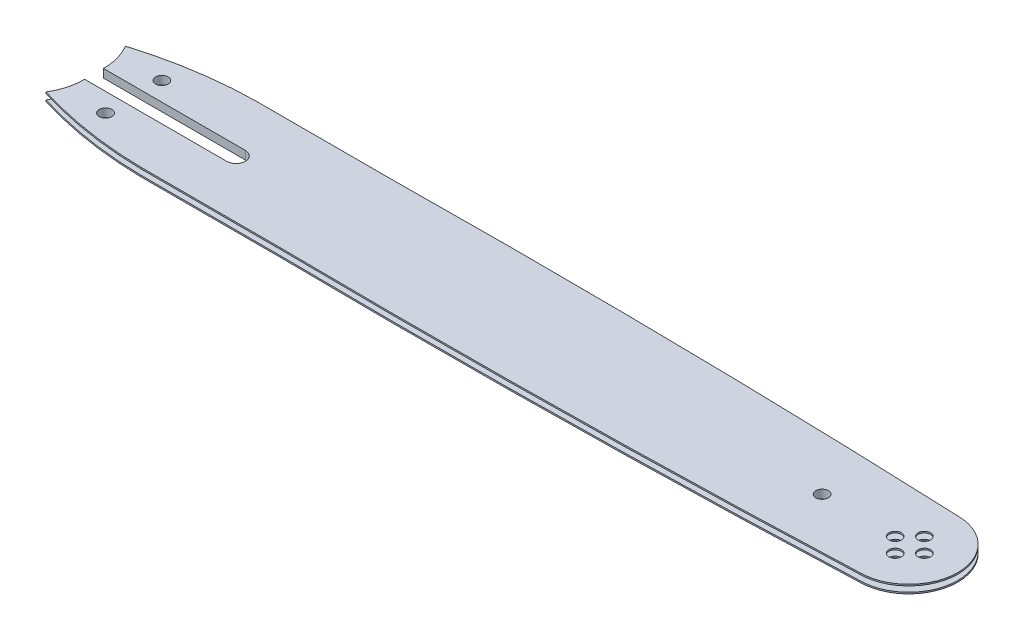
from build123d import *

# Parameters (mm, degrees)
BOSS_EXTRUDE2_DEPTH     = 4
SKETCH1_5_R             = 3
CUT_EXTRUDE3_DEPTH      = 54
SKETCH1_6_R             = 3
CUT_EXTRUDE4_DEPTH      = 35
CUT_EXTRUDE6_DEPTH      = 1.3
CUT_EXTRUDE6_DEPTH_BACK = 1.3


with BuildPart() as part:
    # Sketch1 → Boss-Extrude2 (new body)
    with BuildSketch(Plane(origin=(0, 0, 0), x_dir=(1, 0, 0), z_dir=(0, 1, 0))):
        with BuildLine():
            Line((-71.648984849, 27.5), (-138.40789612, 27.5))
            ThreePointArc((-138.40789612, 27.5), (-165.710949902, 25.175282852), (-192.40789612, 19))
            ThreePointArc((-192.40789612, 19), (-189.370573735, 12.036157899), (-188.40789612, 4.5))
            Line((-188.40789612, 4.5), (-120.40789612, 4.5))
            ThreePointArc((-120.40789612, 4.5), (-115.90789612, 0), (-120.40789612, -4.5))
            Line((-120.40789612, -4.5), (-188.40789612, -4.5))
            ThreePointArc((-188.40789612, -4.5), (-189.370573735, -12.036157899), (-192.40789612, -19))
            ThreePointArc((-192.40789612, -19), (-165.710949902, -25.175282852), (-138.40789612, -27.5))
            Line((-138.40789612, -27.5), (-71.648984849, -27.5))
            ThreePointArc((-71.648984849, -27.5), (65.101994969, -27.347428228), (201.798926373, -23.5))
            ThreePointArc((201.798926373, -23.5), (225.298926373, 0), (201.798926373, 23.5))
            ThreePointArc((201.798926373, 23.5), (65.101994969, 27.347428228), (-71.648984849, 27.5))
        make_face()
    extrude(amount=BOSS_EXTRUDE2_DEPTH)

    # Sketch1_5 → Cut-Extrude3 (cut)
    with BuildSketch(Plane(origin=(0, 0, 0), x_dir=(1, 0, 0), z_dir=(0, 1, 0))):
        with Locations((160.298926373, 0)):
            Circle(SKETCH1_5_R)
        with Locations((195.298926373, 0)):
            Circle(SKETCH1_5_R)
        with Locations((202.298926373, 7)):
            Circle(SKETCH1_5_R)
        with Locations((209.298926373, 0)):
            Circle(SKETCH1_5_R)
        with Locations((202.298926373, -7)):
            Circle(SKETCH1_5_R)
        with Locations((-169.40789612, -13.5)):
            Circle(SKETCH1_5_R)
    extrude(amount=CUT_EXTRUDE3_DEPTH, mode=Mode.SUBTRACT)

    # Sketch1_6 → Cut-Extrude4 (cut)
    with BuildSketch(Plane(origin=(0, 0, 0), x_dir=(1, 0, 0), z_dir=(0, 1, 0))):
        with Locations((-169.40789612, 13.5)):
            Circle(SKETCH1_6_R)
    extrude(amount=CUT_EXTRUDE4_DEPTH, mode=Mode.SUBTRACT)

    # Sketch11 → Cut-Extrude6 (cut, two sides: drawn at the far end of the back side and taken through both)
    with BuildSketch(Plane(origin=(0, 2, 0), x_dir=(1, 0, 0), z_dir=(0, 1, 0)).offset(-CUT_EXTRUDE6_DEPTH_BACK)):
        with BuildLine():
            Line((-138.380243773, -23.5), (-71.624188449, -23.5))
            ThreePointArc((-71.624188449, -23.5), (56.038931481, -23.471555382), (183.66064985, -20.220401783))
            ThreePointArc((183.66064985, -20.220401783), (174.798926373, 0), (183.66064985, 20.220401783))
            ThreePointArc((183.66064985, 20.220401783), (56.038931481, 23.471555382), (-71.624188449, 23.5))
            Line((-71.624188449, 23.5), (-138.380243773, 23.5))
            ThreePointArc((-138.380243773, 23.5), (-164.744814342, 21.277783148), (-190.539098376, 15.388492851))
            ThreePointArc((-190.539098376, 15.388492851), (-191.404952918, 17.229715133), (-192.40789612, 19))
            ThreePointArc((-192.40789612, 19), (-165.710949902, 25.175282852), (-138.40789612, 27.5))
            Line((-138.40789612, 27.5), (-71.648984849, 27.5))
            ThreePointArc((-71.648984849, 27.5), (65.101994969, 27.347428228), (201.798926373, 23.5))
            ThreePointArc((201.798926373, 23.5), (225.298926373, 0), (201.798926373, -23.5))
            ThreePointArc((201.798926373, -23.5), (65.101994969, -27.347428228), (-71.648984849, -27.5))
            Line((-71.648984849, -27.5), (-138.40789612, -27.5))
            ThreePointArc((-138.40789612, -27.5), (-165.710949902, -25.175282852), (-192.40789612, -19))
            ThreePointArc((-192.40789612, -19), (-191.404952918, -17.229715133), (-190.539098376, -15.388492851))
            ThreePointArc((-190.539098376, -15.388492851), (-164.744814342, -21.277783148), (-138.380243773, -23.5))
        make_face()
    extrude(amount=CUT_EXTRUDE6_DEPTH + CUT_EXTRUDE6_DEPTH_BACK, mode=Mode.SUBTRACT)


solid = part.part
